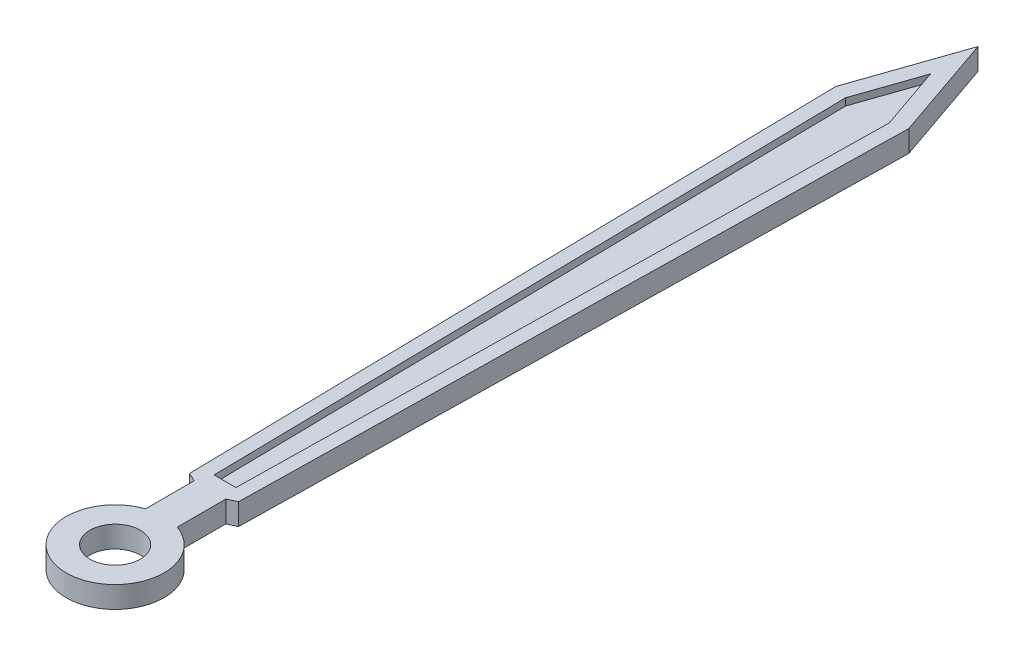
from build123d import *

# Parameters (mm, degrees)
BOSS_EXTRUDE1_DEPTH = 0.3
SKETCH2_R           = 0.35
CUT_EXTRUDE1_DEPTH  = 0.3
CUT_EXTRUDE2_DEPTH  = 0.1


with BuildPart() as part:
    # Sketch1 → Boss-Extrude1 (new body)
    with BuildSketch(Plane(origin=(0, 0, 0), x_dir=(1, 0, 0), z_dir=(0, 1, 0))):
        with BuildLine():
            Line((-0.220137797, 1.319636721), (-0.220137797, 0.643381186))
            ThreePointArc((-0.220137797, 0.643381186), (0, -0.68), (0.220137797, 0.643381186))
            Line((0.220137797, 0.643381186), (0.220137797, 1.319636721))
            Line((0.220137797, 1.319636721), (0.34069528, 1.375278636))
            Line((0.34069528, 1.375278636), (0.507155702, 10.530443548))
            Line((0.507155702, 10.530443548), (0, 12))
            Line((0, 12), (-0.507155702, 10.530443548))
            Line((-0.507155702, 10.530443548), (-0.34069528, 1.375278636))
            Line((-0.34069528, 1.375278636), (-0.220137797, 1.319636721))
        make_face()
    extrude(amount=BOSS_EXTRUDE1_DEPTH)

    # Sketch2 → Cut-Extrude1 (cut)
    with BuildSketch(Plane(origin=(0, 0.3, 0), x_dir=(1, 0, 0), z_dir=(0, 1, 0))):
        Circle(SKETCH2_R)
    extrude(amount=-CUT_EXTRUDE1_DEPTH, mode=Mode.SUBTRACT)

    # Sketch3 → Cut-Extrude2 (cut)
    with BuildSketch(Plane(origin=(0, 0.3, 0), x_dir=(1, 0, 0), z_dir=(0, 1, 0))):
        Polygon((0, 11.340864844), (0.303891547, 10.460295461), (0.151945774, 1.527775516), (-0.151945774, 1.527775516), (-0.303891547, 10.460295461), align=None)
    extrude(amount=-CUT_EXTRUDE2_DEPTH, mode=Mode.SUBTRACT)


solid = part.part
